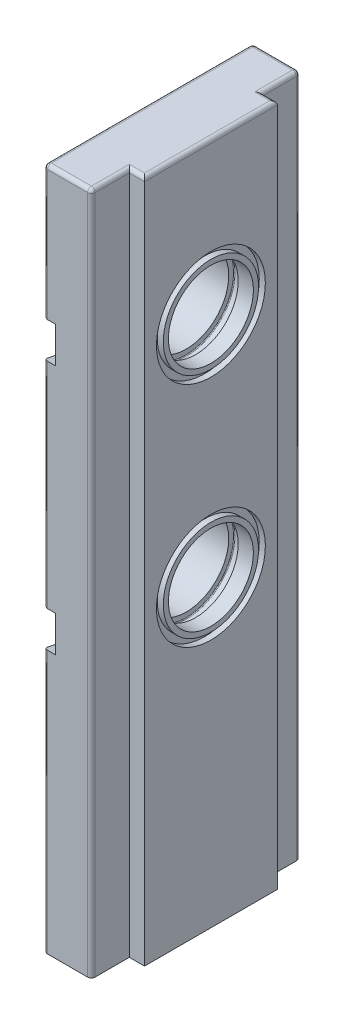
from build123d import *

# Parameters (mm, degrees)
BOSS_EXTRUDE1_DEPTH   = 180
SKETCH3_R             = 11.2
CUT_EXTRUDE1_DEPTH    = 17.5
SKETCH11_W            = 1.6
SKETCH11_H            = 1.8
LPATTERN1_COUNT       = 2
LPATTERN1_PITCH       = 60
M6_TAPPED_HOLE1_D     = 5
M6_TAPPED_HOLE1_DEPTH = 27
M6_TAPPED_HOLE1_TIP   = 1.502151548
CUT_EXTRUDE2_DEPTH    = 3
FILLET1_R             = 1


with BuildPart() as part:
    # Sketch1 → Boss-Extrude1 (new body)
    with BuildSketch(Plane(origin=(0, 0, 0), x_dir=(1, 0, 0), z_dir=(0, 1, 0))):
        Polygon((0, 0), (0, 55), (12.5, 55), (12.5, 45), (16.5, 45), (16.5, 10), (12.5, 10), (12.5, 0), align=None)
    extrude(amount=BOSS_EXTRUDE1_DEPTH)

    # Sketch3 → Cut-Extrude1 (cut, through all)
    with BuildSketch(Plane(origin=(16.5, 0, 0), x_dir=(0, 0, -1), z_dir=(1, 0, 0))):
        with Locations((27.5, 80)):
            Circle(SKETCH3_R)
    cut_extrude1 = extrude(amount=-CUT_EXTRUDE1_DEPTH, mode=Mode.SUBTRACT)

    # Sketch11 → Cut-Revolve1 (revolve, cut)
    with BuildSketch(Plane.XY.offset(-27.5)):
        with BuildLine():
            Line((10, 69.15), (12.5, 69.15))
            Line((12.5, 69.15), (12.5, 67.55))
            ThreePointArc((12.5, 67.55), (12.441421356, 67.408578644), (12.3, 67.35))
            Line((12.3, 67.35), (10.2, 67.35))
            ThreePointArc((10.2, 67.35), (10.058578644, 67.408578644), (10, 67.55))
            Line((10, 67.55), (10, 69.15))
        make_face()
        with Locations((15.7, 66.55)):
            Rectangle(SKETCH11_W, SKETCH11_H)
    cut_revolve1 = revolve(axis=Axis((16.5, 80, -27.5), (-1, 0, 0)), mode=Mode.SUBTRACT)

    # LPattern1: Cut-Extrude1, Cut-Revolve1 ×2
    with Locations(*[(0, i * LPATTERN1_PITCH, 0) for i in range(1, LPATTERN1_COUNT)]):
        add(cut_extrude1, mode=Mode.SUBTRACT)
        add(cut_revolve1, mode=Mode.SUBTRACT)

    # M6 Tapped Hole1
    with Locations(Plane.XZ):
        with Locations((6.5, -12.5), (6.5, -42.5)):
            Hole(M6_TAPPED_HOLE1_D / 2, depth=M6_TAPPED_HOLE1_DEPTH)
            with Locations((0, 0, -(M6_TAPPED_HOLE1_DEPTH + M6_TAPPED_HOLE1_TIP / 2))):  # 118° drill point
                Cone(0, M6_TAPPED_HOLE1_D / 2, M6_TAPPED_HOLE1_TIP, mode=Mode.SUBTRACT)

    # Sketch15 → Cut-Extrude2 (cut)
    with BuildSketch(Plane.ZY):
        Polygon((0, 144.75), (-9.5, 146.75), (-9.5, 133.25), (0, 135.25), align=None)
        Polygon((0, 78.8), (-9.5, 80.8), (-9.5, 67.3), (0, 69.3), align=None)
        Polygon((-55, 39.4), (-45.5, 41.4), (-45.5, 27.9), (-55, 29.9), align=None)
    extrude(amount=-CUT_EXTRUDE2_DEPTH, mode=Mode.SUBTRACT)

    # Fillet1
    fillet1_edges = [part.edges().sort_by_distance(p)[0] for p in [
        (14.5, 180, -10),
        (16.5, 180, -27.5),
        (0, 162.375, 0),
        (0, 109.7, -55),
        (12.5, 90, -55),
        (12.5, 90, 0),
        (14.5, 180, -45),
        (12.5, 180, -50),
        (6.25, 180, -55),
        (0, 180, -27.5),
        (6.25, 180, 0),
        (12.5, 180, -5),
        (0, 107.025, 0),
        (0, 34.65, 0),
        (0, 14.95, -55),
    ]]
    fillet(fillet1_edges, radius=FILLET1_R)


solid = part.part
